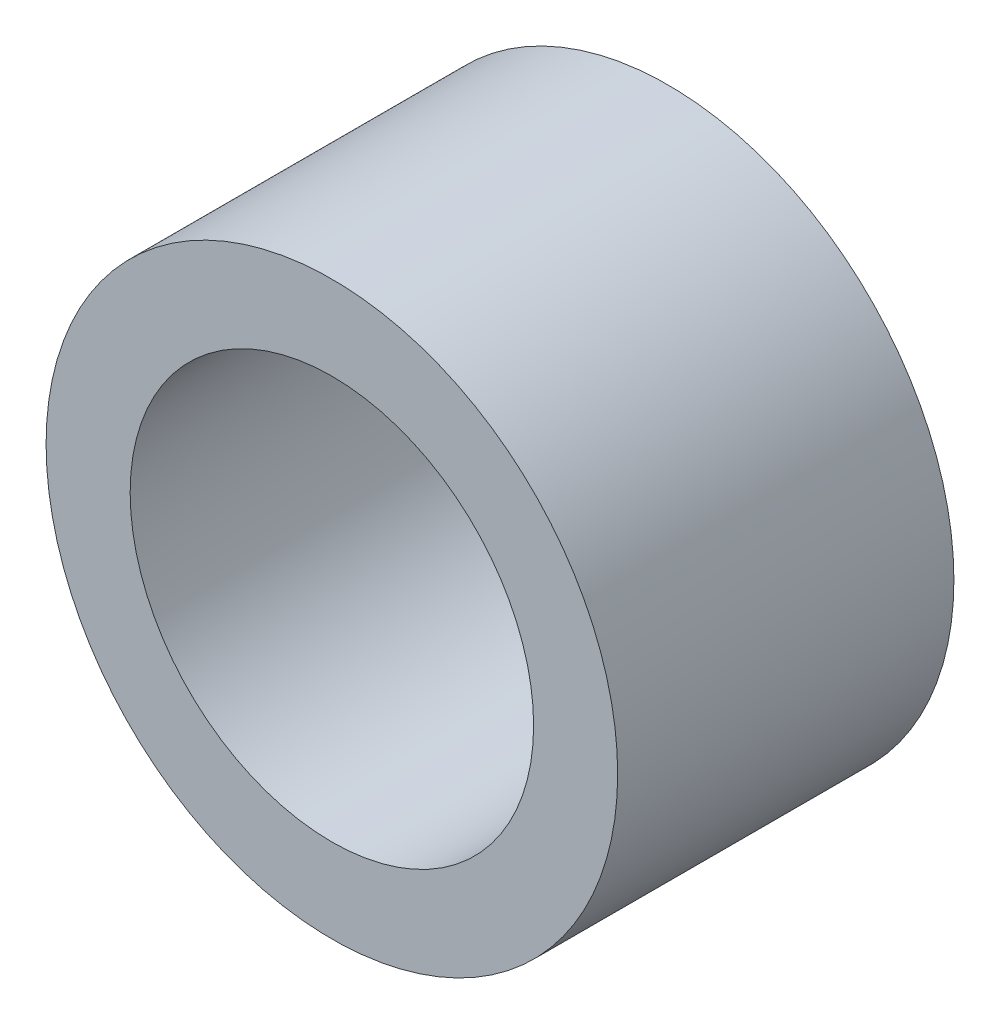
from build123d import *

# Parameters (mm, degrees)
SKETCH1_R           = 17
SKETCH1_R_2         = 12
BOSS_EXTRUDE1_DEPTH = 10


with BuildPart() as part:
    # Sketch1 → Boss-Extrude1 (new body, symmetric)
    with BuildSketch(Plane.XY):
        Circle(SKETCH1_R)
        Circle(SKETCH1_R_2, mode=Mode.SUBTRACT)
    extrude(amount=BOSS_EXTRUDE1_DEPTH, both=True)


solid = part.part
